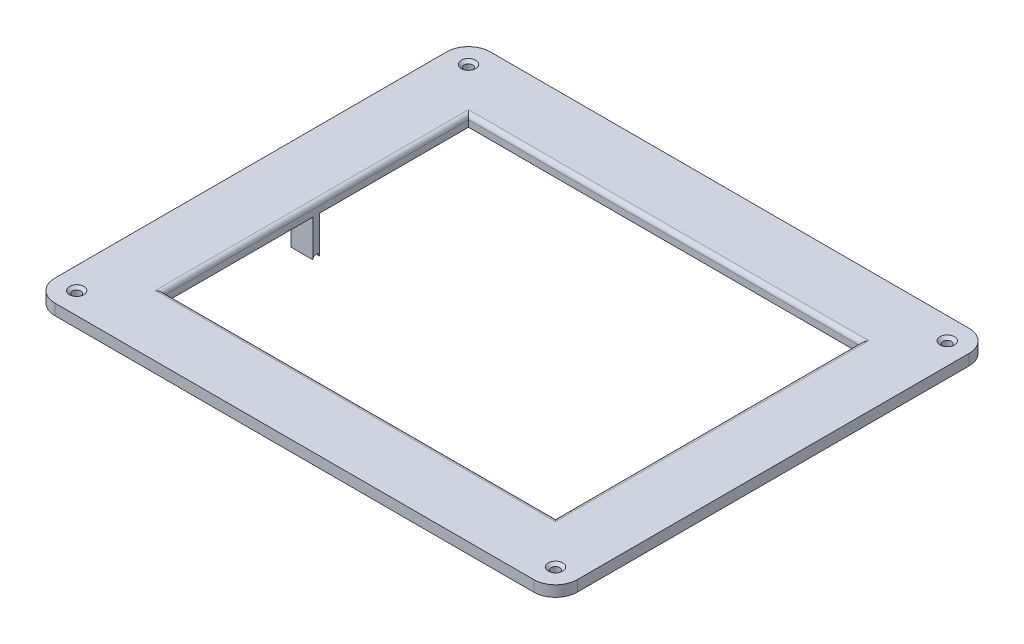
from build123d import *

# Parameters (mm, degrees)
SKETCH1_W                                         = 304.8
SKETCH1_H                                         = 254
BOSS_EXTRUDE1_DEPTH                               = 6.35
SKETCH2_W                                         = 228.6
SKETCH2_H                                         = 177.8
CUT_EXTRUDE1_DEPTH                                = 6.35
FILLET1_R                                         = 2.54
FILLET5_R                                         = 12.7
SKETCH6_W                                         = 12.7
SKETCH6_H                                         = 3.81
BOSS_EXTRUDE3_DEPTH                               = 21.59
SKETCH8_R                                         = 1.905
CUT_EXTRUDE5_DEPTH                                = 12.7
CSK_FOR_8_FLAT_HEAD_MACHINE_SCREW_100_D           = 4.9149
CSK_FOR_8_FLAT_HEAD_MACHINE_SCREW_100_DEPTH       = 10.668
CSK_FOR_8_FLAT_HEAD_MACHINE_SCREW_100_CSINK_D     = 8.4328
CSK_FOR_8_FLAT_HEAD_MACHINE_SCREW_100_CSINK_ANGLE = 100
CSK_FOR_8_FLAT_HEAD_MACHINE_SCREW_100_TIP         = 1.476584928


with BuildPart() as part:
    # Sketch1 → Boss-Extrude1 (new body)
    with BuildSketch(Plane(origin=(0, 0, 0), x_dir=(1, 0, 0), z_dir=(0, 1, 0))):
        Rectangle(SKETCH1_W, SKETCH1_H)
    extrude(amount=BOSS_EXTRUDE1_DEPTH)

    # Sketch2 → Cut-Extrude1 (cut)
    with BuildSketch(Plane(origin=(0, 6.35, 0), x_dir=(1, 0, 0), z_dir=(0, 1, 0))):
        Rectangle(SKETCH2_W, SKETCH2_H)
    extrude(amount=-CUT_EXTRUDE1_DEPTH, mode=Mode.SUBTRACT)

    # Fillet1
    fillet1_edges = [part.edges().sort_by_distance(p)[0] for p in [
        (114.3, 6.35, 0),
        (0, 6.35, -88.9),
        (-114.3, 6.35, 0),
        (0, 6.35, 88.9),
    ]]
    fillet(fillet1_edges, radius=FILLET1_R)

    # Fillet5
    fillet5_edges = [part.edges().sort_by_distance(p)[0] for p in [
        (152.4, 3.175, 127),
        (-152.4, 3.175, 127),
        (-152.4, 3.175, -127),
        (152.4, 3.175, -127),
    ]]
    fillet(fillet5_edges, radius=FILLET5_R)

    # Sketch6 → Boss-Extrude3 (add)
    with BuildSketch(Plane.XZ):
        with Locations((-120.65, 0)):
            Rectangle(SKETCH6_W, SKETCH6_H)
    boss_extrude3 = extrude(amount=BOSS_EXTRUDE3_DEPTH)

    # Sketch8 → Cut-Extrude5 (cut)
    with BuildSketch(Plane.ZY.offset(127)):
        with Locations((0, -21.59)):
            Circle(SKETCH8_R)
    cut_extrude5 = extrude(amount=-CUT_EXTRUDE5_DEPTH, mode=Mode.SUBTRACT)

    # Mirror1: Boss-Extrude3, Cut-Extrude5 across plane
    add(boss_extrude3.mirror(Plane(origin=(0, 0, 0), x_dir=(0, 0, 1), z_dir=(1, 0, 0))))
    add(cut_extrude5.mirror(Plane(origin=(0, 0, 0), x_dir=(0, 0, 1), z_dir=(1, 0, 0))), mode=Mode.SUBTRACT)

    # CSK for #8 Flat Head Machine Screw (100)1
    with Locations(Plane(origin=(0, 6.35, 0), x_dir=(1, 0, 0), z_dir=(0, 1, 0))):
        with Locations((-139.7, -114.3), (139.7, -114.3), (139.7, 114.3), (-139.7, 114.3)):
            CounterSinkHole(CSK_FOR_8_FLAT_HEAD_MACHINE_SCREW_100_D / 2, CSK_FOR_8_FLAT_HEAD_MACHINE_SCREW_100_CSINK_D / 2, depth=CSK_FOR_8_FLAT_HEAD_MACHINE_SCREW_100_DEPTH, counter_sink_angle=CSK_FOR_8_FLAT_HEAD_MACHINE_SCREW_100_CSINK_ANGLE)
            with Locations((0, 0, -(CSK_FOR_8_FLAT_HEAD_MACHINE_SCREW_100_DEPTH + CSK_FOR_8_FLAT_HEAD_MACHINE_SCREW_100_TIP / 2))):  # 118° drill point
                Cone(0, CSK_FOR_8_FLAT_HEAD_MACHINE_SCREW_100_D / 2, CSK_FOR_8_FLAT_HEAD_MACHINE_SCREW_100_TIP, mode=Mode.SUBTRACT)


solid = part.part
